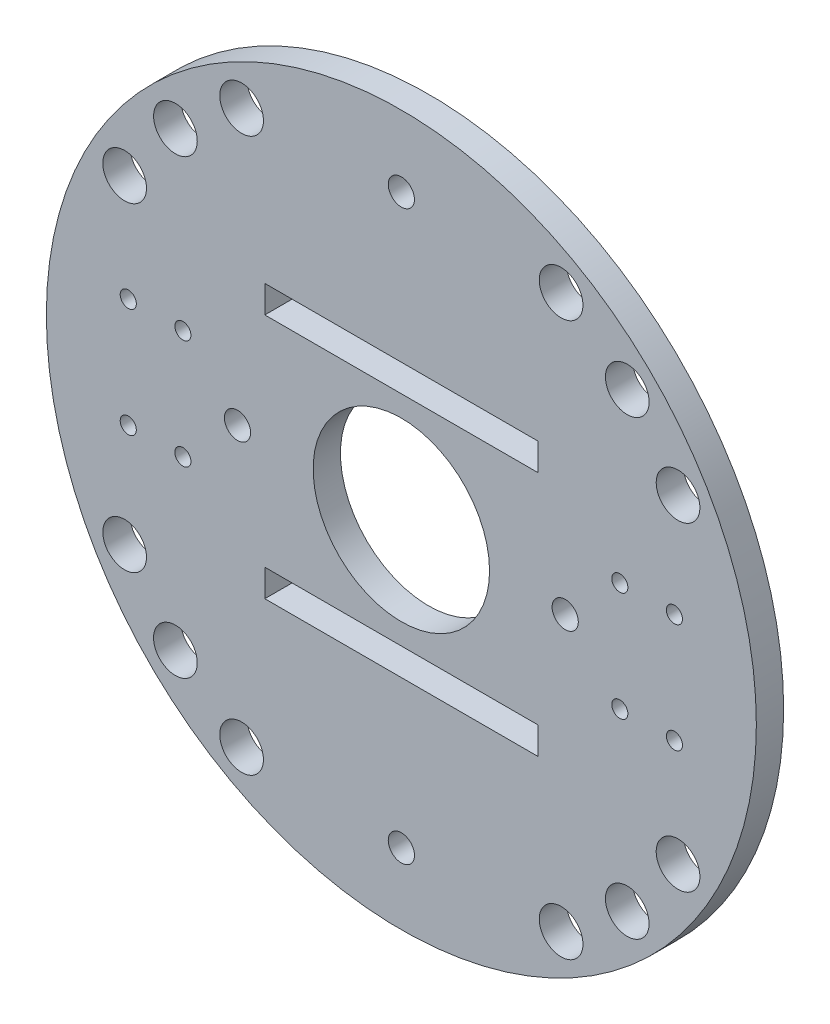
from build123d import *

# Parameters (mm, degrees)
SKETCH1_R           = 65
SKETCH1_R_2         = 16.15
SKETCH1_R_3         = 2.4
SKETCH1_R_4         = 4
SKETCH1_R_5         = 1.475
SKETCH1_W           = 50
SKETCH1_H           = 5
BOSS_EXTRUDE1_DEPTH = 5


with BuildPart() as part:
    # Sketch1 → Boss-Extrude1 (new body)
    with BuildSketch(Plane.XY):
        Circle(SKETCH1_R)
        Circle(SKETCH1_R_2, mode=Mode.SUBTRACT)
        with Locations((0, 52)):
            Circle(SKETCH1_R_3, mode=Mode.SUBTRACT)
        with Locations((-30, 0)):
            Circle(SKETCH1_R_3, mode=Mode.SUBTRACT)
        with Locations((0, -52)):
            Circle(SKETCH1_R_3, mode=Mode.SUBTRACT)
        with Locations((30, 0)):
            Circle(SKETCH1_R_3, mode=Mode.SUBTRACT)
        with Locations((-41.365746699, 41.365746699)):
            Circle(SKETCH1_R_4, mode=Mode.SUBTRACT)
        with Locations((-29.25, 50.662486121)):
            Circle(SKETCH1_R_4, mode=Mode.SUBTRACT)
        with Locations((-50.662486121, 29.25)):
            Circle(SKETCH1_R_4, mode=Mode.SUBTRACT)
        with Locations((50.662486121, 29.25)):
            Circle(SKETCH1_R_4, mode=Mode.SUBTRACT)
        with Locations((41.365746699, 41.365746699)):
            Circle(SKETCH1_R_4, mode=Mode.SUBTRACT)
        with Locations((29.25, 50.662486121)):
            Circle(SKETCH1_R_4, mode=Mode.SUBTRACT)
        with Locations((50.662486121, -29.25)):
            Circle(SKETCH1_R_4, mode=Mode.SUBTRACT)
        with Locations((41.365746699, -41.365746699)):
            Circle(SKETCH1_R_4, mode=Mode.SUBTRACT)
        with Locations((29.25, -50.662486121)):
            Circle(SKETCH1_R_4, mode=Mode.SUBTRACT)
        with Locations((-29.25, -50.662486121)):
            Circle(SKETCH1_R_4, mode=Mode.SUBTRACT)
        with Locations((-41.365746699, -41.365746699)):
            Circle(SKETCH1_R_4, mode=Mode.SUBTRACT)
        with Locations((-50.662486121, -29.25)):
            Circle(SKETCH1_R_4, mode=Mode.SUBTRACT)
        with Locations((-40, 10)):
            Circle(SKETCH1_R_5, mode=Mode.SUBTRACT)
        with Locations((-50, 10)):
            Circle(SKETCH1_R_5, mode=Mode.SUBTRACT)
        with Locations((-40, -10)):
            Circle(SKETCH1_R_5, mode=Mode.SUBTRACT)
        with Locations((-50, -10)):
            Circle(SKETCH1_R_5, mode=Mode.SUBTRACT)
        with Locations((50, -10)):
            Circle(SKETCH1_R_5, mode=Mode.SUBTRACT)
        with Locations((40, -10)):
            Circle(SKETCH1_R_5, mode=Mode.SUBTRACT)
        with Locations((40, 10)):
            Circle(SKETCH1_R_5, mode=Mode.SUBTRACT)
        with Locations((50, 10)):
            Circle(SKETCH1_R_5, mode=Mode.SUBTRACT)
        with Locations((0, -22.5)):
            Rectangle(SKETCH1_W, SKETCH1_H, mode=Mode.SUBTRACT)
        with Locations((0, 22.5)):
            Rectangle(SKETCH1_W, SKETCH1_H, mode=Mode.SUBTRACT)
    extrude(amount=BOSS_EXTRUDE1_DEPTH)


solid = part.part
